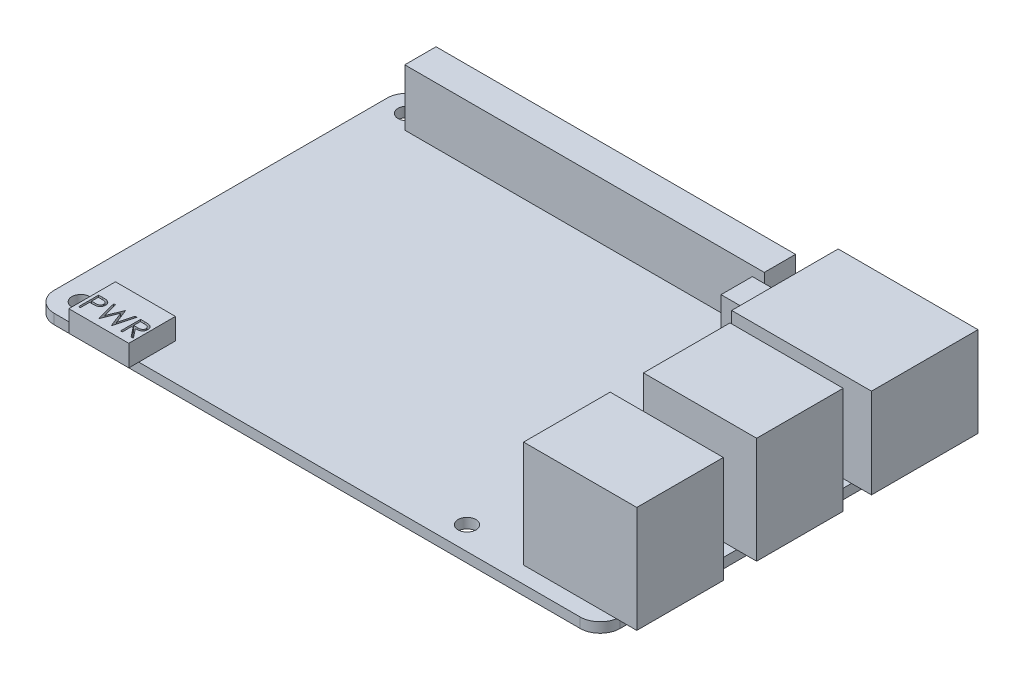
from build123d import *

# Parameters (mm, degrees)
SKETCH1_W           = 85
SKETCH1_H           = 56
SKETCH1_R           = 1.35
BOSS_EXTRUDE1_DEPTH = 1.5
FILLET1_R           = 3
SKETCH2_W           = 17
SKETCH2_H           = 13
BOSS_EXTRUDE2_DEPTH = 16
SKETCH3_W           = 21
SKETCH3_H           = 16
BOSS_EXTRUDE3_DEPTH = 13.5
SKETCH4_W           = 54
SKETCH4_H           = 4.7
SKETCH4_W_2         = 4.7
BOSS_EXTRUDE4_DEPTH = 8.5
SKETCH5_W           = 9
SKETCH5_H           = 7
BOSS_EXTRUDE5_DEPTH = 3.2
CUT_EXTRUDE1_DEPTH  = 1


with BuildPart() as part:
    # Sketch1 → Boss-Extrude1 (new body)
    with BuildSketch(Plane(origin=(0, 0, 0), x_dir=(1, 0, 0), z_dir=(0, 1, 0))):
        with Locations((42.5, 28)):
            Rectangle(SKETCH1_W, SKETCH1_H)
        with Locations((3.5, 52.5)):
            Circle(SKETCH1_R, mode=Mode.SUBTRACT)
        with Locations((3.5, 3.5)):
            Circle(SKETCH1_R, mode=Mode.SUBTRACT)
        with Locations((61.5, 3.5)):
            Circle(SKETCH1_R, mode=Mode.SUBTRACT)
        with Locations((61.5, 52.5)):
            Circle(SKETCH1_R, mode=Mode.SUBTRACT)
    extrude(amount=BOSS_EXTRUDE1_DEPTH)

    # Fillet1
    fillet1_edges = [part.edges().sort_by_distance(p)[0] for p in [
        (0, 0.75, -56),
        (85, 0.75, -56),
        (85, 0.75, 0),
        (0, 0.75, 0),
    ]]
    fillet(fillet1_edges, radius=FILLET1_R)

    # Sketch2 → Boss-Extrude2 (add)
    with BuildSketch(Plane(origin=(0, 1.5, 0), x_dir=(1, 0, 0), z_dir=(0, 1, 0))):
        with Locations((79.5, 27)):
            Rectangle(SKETCH2_W, SKETCH2_H)
        with Locations((79.5, 9)):
            Rectangle(SKETCH2_W, SKETCH2_H)
    extrude(amount=BOSS_EXTRUDE2_DEPTH)

    # Sketch3 → Boss-Extrude3 (add)
    with BuildSketch(Plane(origin=(0, 1.5, 0), x_dir=(1, 0, 0), z_dir=(0, 1, 0))):
        with Locations((77.5, 45.75)):
            Rectangle(SKETCH3_W, SKETCH3_H)
    extrude(amount=BOSS_EXTRUDE3_DEPTH)

    # Sketch4 → Boss-Extrude4 (add)
    with BuildSketch(Plane(origin=(0, 1.5, 0), x_dir=(1, 0, 0), z_dir=(0, 1, 0))):
        with Locations((32.5, 52.5)):
            Rectangle(SKETCH4_W, SKETCH4_H)
        with Locations((61.5, 46.36)):
            Rectangle(SKETCH4_W_2, SKETCH4_H)
    extrude(amount=BOSS_EXTRUDE4_DEPTH)

    # Sketch5 → Boss-Extrude5 (add)
    with BuildSketch(Plane(origin=(0, 1.5, 0), x_dir=(1, 0, 0), z_dir=(0, 1, 0))):
        with Locations((11.2, 2)):
            Rectangle(SKETCH5_W, SKETCH5_H)
    extrude(amount=BOSS_EXTRUDE5_DEPTH)

    # Sketch6 → Cut-Extrude1 (cut)
    with BuildSketch(Plane(origin=(0, 4.7, 0), x_dir=(1, 0, 0), z_dir=(0, 1, 0))):
        with BuildLine():
            Line((7.161538462, 2.5), (7.749879808, 2.5))
            add(Edge.make_bspline(
                [(7.749879808, 2.5), (7.790346299, 2.499955518), (7.867881893, 2.499870287), (7.979066226, 2.497286219), (8.080045996, 2.493834769), (8.170603465, 2.489050289), (8.251017264, 2.483396069), (8.32092352, 2.475465749), (8.380871712, 2.467185496), (8.416791525, 2.458767148), (8.433173077, 2.454927885)],
                knots=[0, 0, 0, 0, 0.000121396, 0.0002326, 0.000333625, 0.000424498, 0.000504651, 0.000575397, 0.000635571, 0.000686023, 0.000686023, 0.000686023, 0.000686023], degree=3))
            add(Edge.make_bspline(
                [(8.433173077, 2.454927885), (8.453910392, 2.449251928), (8.494896372, 2.43803376), (8.553954409, 2.415564855), (8.610143419, 2.388922999), (8.663656184, 2.358559622), (8.713835112, 2.323171995), (8.761428862, 2.284194609), (8.806017416, 2.24072755), (8.847350038, 2.193258344), (8.885308436, 2.142583879), (8.917991021, 2.087947682), (8.945357215, 2.030269422), (8.968828591, 1.969589218), (8.985721552, 1.905397512), (8.998447466, 1.83814033), (9.006524861, 1.767824881), (9.007298485, 1.719773566), (9.007692308, 1.6953125)],
                knots=[0, 0, 0, 0, 6.4471e-05, 0.000127423, 0.000189252, 0.000250897, 0.000311748, 0.000373229, 0.000435277, 0.000498312, 0.000561894, 0.00062497, 0.000688943, 0.000753232, 0.000819855, 0.000887745, 0.00095849, 0.001031847, 0.001031847, 0.001031847, 0.001031847], degree=3))
            add(Edge.make_bspline(
                [(9.007692308, 1.6953125), (9.007331086, 1.670645834), (9.006624333, 1.622383837), (8.998141803, 1.551778589), (8.986715924, 1.484305684), (8.969147022, 1.420114726), (8.946136445, 1.359586923), (8.919143257, 1.301797295), (8.886585945, 1.247729005), (8.849176091, 1.197185762), (8.807560439, 1.150120122), (8.761915063, 1.106873156), (8.712424241, 1.067698009), (8.659245257, 1.032506857), (8.601859672, 1.00211576), (8.541137826, 0.974895213), (8.476551927, 0.952034304), (8.431858343, 0.940008537), (8.409134615, 0.933894231)],
                knots=[0, 0, 0, 0, 7.3957e-05, 0.000144703, 0.000213075, 0.000279118, 0.000343969, 0.000407141, 0.000470216, 0.000532959, 0.000595542, 0.000658457, 0.00072134, 0.000784678, 0.000849476, 0.000915925, 0.000984163, 0.001054742, 0.001054742, 0.001054742, 0.001054742], degree=3))
            add(Edge.make_bspline(
                [(8.409134615, 0.933894231), (8.390339758, 0.92989739), (8.349149734, 0.921138081), (8.281313115, 0.911359403), (8.202331356, 0.903012888), (8.112312259, 0.89675477), (8.011336626, 0.891397312), (7.899349834, 0.887138946), (7.776132054, 0.884799071), (7.690185273, 0.884678391), (7.6453125, 0.884615385)],
                knots=[0, 0, 0, 0, 5.7633e-05, 0.000126306, 0.00020548, 0.000295866, 0.000396973, 0.00050883, 0.000632051, 0.000766668, 0.000766668, 0.000766668, 0.000766668], degree=3))
            Line((7.6453125, 0.884615385), (7.430769231, 0.884615385))
            Line((7.430769231, 0.884615385), (7.430769231, -0.5))
            Line((7.430769231, -0.5), (7.161538462, -0.5))
            Line((7.161538462, -0.5), (7.161538462, 2.5))
        make_face()
        with BuildLine():
            Line((7.430769231, 2.192307692), (7.430769231, 1.192307692))
            Line((7.430769231, 1.192307692), (7.956009615, 1.185697115))
            add(Edge.make_bspline(
                [(7.956009615, 1.185697115), (7.981655266, 1.185683861), (8.031163666, 1.185658273), (8.102680429, 1.189074179), (8.169031246, 1.193017493), (8.230012311, 1.198791142), (8.285651112, 1.206952219), (8.336040423, 1.215190852), (8.380789522, 1.227109734), (8.433160267, 1.243158079), (8.491517422, 1.270528893), (8.555003892, 1.31025737), (8.608807251, 1.360897977), (8.655365791, 1.417836118), (8.692313687, 1.481178229), (8.71936168, 1.548951603), (8.735254101, 1.620461188), (8.737385124, 1.669393879), (8.738461538, 1.694110577)],
                knots=[0, 0, 0, 0, 7.6925e-05, 0.000148503, 0.000214742, 0.000276334, 0.000332172, 0.000383451, 0.000429365, 0.000470988, 0.000547631, 0.000621978, 0.000694704, 0.000768194, 0.000841992, 0.000913749, 0.000986363, 0.001060479, 0.001060479, 0.001060479, 0.001060479], degree=3))
            add(Edge.make_bspline(
                [(8.738461538, 1.694110577), (8.73737927, 1.718229303), (8.735227854, 1.766174345), (8.719237115, 1.836441854), (8.692366274, 1.903501029), (8.655117764, 1.966049388), (8.609911082, 2.022782648), (8.557368788, 2.0720659), (8.497614564, 2.111684502), (8.442030366, 2.137255887), (8.39265792, 2.15286898), (8.349773383, 2.163793129), (8.301352805, 2.172515077), (8.247380423, 2.179577508), (8.188274565, 2.185623332), (8.123527438, 2.189725598), (8.053384315, 2.192126846), (8.00468954, 2.192245951), (7.979447115, 2.192307692)],
                knots=[0, 0, 0, 0, 7.2318e-05, 0.000143759, 0.000214957, 0.000288238, 0.00036135, 0.000431937, 0.000503441, 0.000575509, 0.000614659, 0.000658677, 0.000708183, 0.000762152, 0.00082195, 0.000886391, 0.000956744, 0.001032468, 0.001032468, 0.001032468, 0.001032468], degree=3))
            Line((7.979447115, 2.192307692), (7.430769231, 2.192307692))
        make_face(mode=Mode.SUBTRACT)
        Polygon((9.430769231, 2.5), (9.709014423, 2.5), (10.296153846, 0.299879808), (11.169350962, 2.5), (11.208413462, 2.5), (12.065384615, 0.314903846), (12.655528846, 2.5), (12.930769231, 2.5), (12.121875, -0.5), (12.083413462, -0.5), (11.180769231, 1.794471154), (10.267307692, -0.5), (10.228846154, -0.5), align=None)
        with BuildLine():
            Line((13.469230769, 2.5), (14.069591346, 2.5))
            add(Edge.make_bspline(
                [(14.069591346, 2.5), (14.109655171, 2.499866641), (14.186582152, 2.499610576), (14.296787812, 2.498182779), (14.396925324, 2.494090474), (14.486942329, 2.490568831), (14.566837176, 2.484147167), (14.636854854, 2.47800947), (14.69667288, 2.469974903), (14.73288361, 2.462513112), (14.749278846, 2.459134615)],
                knots=[0, 0, 0, 0, 0.000120194, 0.000230785, 0.00033061, 0.000420853, 0.000501006, 0.00057103, 0.000631713, 0.000681921, 0.000681921, 0.000681921, 0.000681921], degree=3))
            add(Edge.make_bspline(
                [(14.749278846, 2.459134615), (14.771227381, 2.453711674), (14.814656229, 2.442981476), (14.877184857, 2.420301818), (14.936768564, 2.394056426), (14.993159842, 2.36323038), (15.046076234, 2.327594854), (15.096063358, 2.287765035), (15.14334804, 2.243958859), (15.186018009, 2.195071852), (15.226251482, 2.143783415), (15.26018459, 2.088323052), (15.289435859, 2.030327457), (15.312724873, 1.969206813), (15.331477422, 1.905553866), (15.344699913, 1.83879204), (15.352629502, 1.76922549), (15.353436807, 1.721775854), (15.353846154, 1.697716346)],
                knots=[0, 0, 0, 0, 6.7784e-05, 0.000134121, 0.000199228, 0.000262969, 0.00032664, 0.000390368, 0.000454569, 0.000519698, 0.000584846, 0.000649886, 0.000714388, 0.000779453, 0.000845823, 0.000913238, 0.000983386, 0.001055542, 0.001055542, 0.001055542, 0.001055542], degree=3))
            add(Edge.make_bspline(
                [(15.353846154, 1.697716346), (15.352587013, 1.657743399), (15.350130102, 1.579745827), (15.32722287, 1.466550786), (15.289700139, 1.360959945), (15.237994463, 1.263106255), (15.172149198, 1.17489713), (15.093013663, 1.097419597), (15.00054371, 1.032585386), (14.914461439, 0.98762584), (14.838420696, 0.958831918), (14.775820714, 0.938572182), (14.707534733, 0.922919069), (14.634217018, 0.908896098), (14.555562456, 0.898308932), (14.471759565, 0.890554708), (14.382748578, 0.885708381), (14.321600804, 0.884986662), (14.290144231, 0.884615385)],
                knots=[0, 0, 0, 0, 0.000119809, 0.000233778, 0.000344785, 0.000455008, 0.000564504, 0.000673722, 0.000785778, 0.000902162, 0.000963991, 0.001029562, 0.001099382, 0.001173991, 0.001253456, 0.001337355, 0.001426427, 0.001520795, 0.001520795, 0.001520795, 0.001520795], degree=3))
            Line((14.290144231, 0.884615385), (15.392307692, -0.5))
            Line((15.392307692, -0.5), (15.059375, -0.5))
            Line((15.059375, -0.5), (13.957211538, 0.884615385))
            Line((13.957211538, 0.884615385), (13.738461538, 0.884615385))
            Line((13.738461538, 0.884615385), (13.738461538, -0.5))
            Line((13.738461538, -0.5), (13.469230769, -0.5))
            Line((13.469230769, -0.5), (13.469230769, 2.5))
        make_face()
        with BuildLine():
            Line((13.738461538, 2.192307692), (13.738461538, 1.192307692))
            Line((13.738461538, 1.192307692), (14.287740385, 1.188100962))
            add(Edge.make_bspline(
                [(14.287740385, 1.188100962), (14.313386132, 1.188089616), (14.363094896, 1.188067625), (14.435009751, 1.191490861), (14.501969847, 1.195385134), (14.563719063, 1.201341716), (14.620284985, 1.209018349), (14.671639339, 1.218620907), (14.717865955, 1.229808389), (14.771778988, 1.247124068), (14.831981729, 1.274557798), (14.897408694, 1.314471083), (14.953124984, 1.364673185), (15.000197437, 1.422079005), (15.038022664, 1.485195789), (15.064690139, 1.553266963), (15.081612233, 1.624574047), (15.083608129, 1.673583854), (15.084615385, 1.698317308)],
                knots=[0, 0, 0, 0, 7.6925e-05, 0.000149103, 0.000215943, 0.000278133, 0.000335161, 0.00038714, 0.000434802, 0.000477752, 0.000556833, 0.000632702, 0.000706764, 0.000780634, 0.000854737, 0.000926494, 0.00099924, 0.001073356, 0.001073356, 0.001073356, 0.001073356], degree=3))
            add(Edge.make_bspline(
                [(15.084615385, 1.698317308), (15.083584995, 1.722442942), (15.081543139, 1.770251147), (15.064872766, 1.840241927), (15.036681868, 1.906299313), (14.998691378, 1.968154586), (14.952406388, 2.024302359), (14.898133977, 2.072342776), (14.837358096, 2.111985175), (14.780554211, 2.137317501), (14.729782029, 2.152848804), (14.685699464, 2.163778373), (14.635889625, 2.172559346), (14.580110661, 2.179594827), (14.518600692, 2.185641922), (14.451048705, 2.189714875), (14.377902893, 2.192126758), (14.327205524, 2.192245977), (14.300961538, 2.192307692)],
                knots=[0, 0, 0, 0, 7.2318e-05, 0.000143308, 0.000214407, 0.000286967, 0.000360372, 0.000431889, 0.000503565, 0.000577276, 0.000617571, 0.000662756, 0.000713443, 0.0007692, 0.00083139, 0.000898829, 0.000972186, 0.001050914, 0.001050914, 0.001050914, 0.001050914], degree=3))
            Line((14.300961538, 2.192307692), (13.738461538, 2.192307692))
        make_face(mode=Mode.SUBTRACT)
    extrude(amount=-CUT_EXTRUDE1_DEPTH, mode=Mode.SUBTRACT)


solid = part.part
